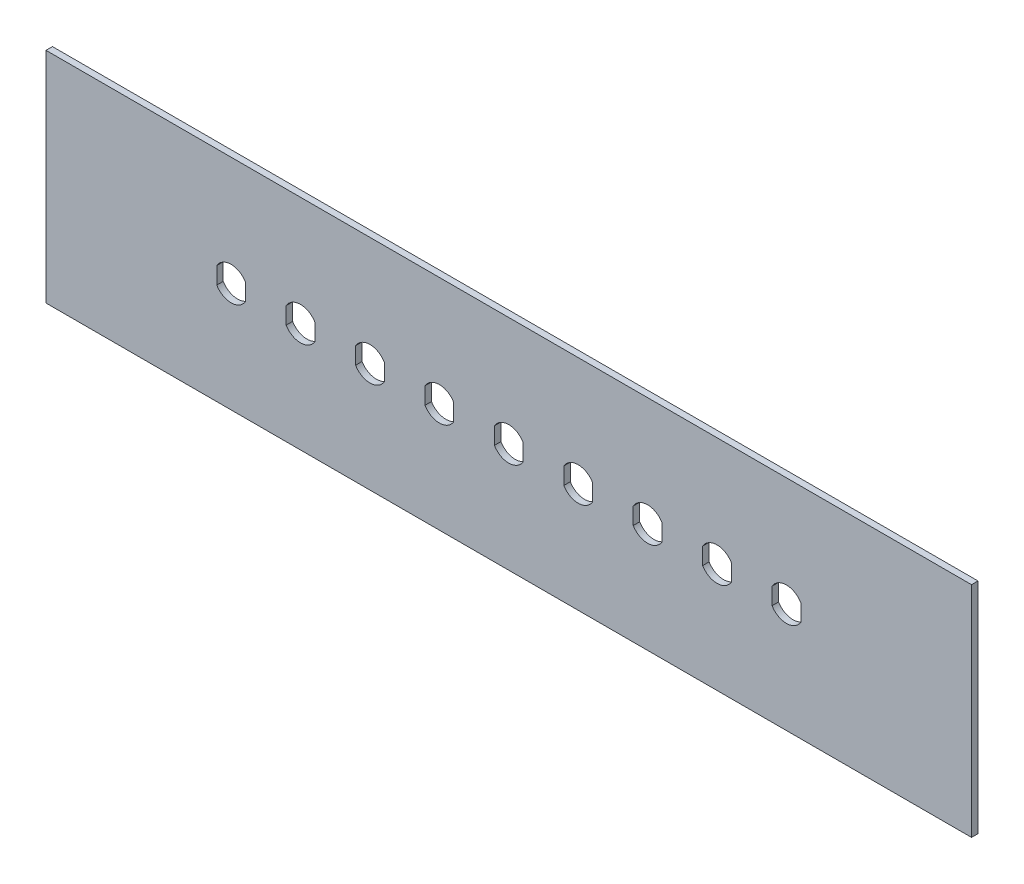
from build123d import *

# Parameters (mm, degrees)
SKETCH1_W           = 254
SKETCH1_H           = 60.071
BOSS_EXTRUDE1_DEPTH = 1.778
CUT_EXTRUDE2_DEPTH  = 262.012808737
LPATTERN1_COUNT     = 9
LPATTERN1_PITCH     = 19.05


with BuildPart() as part:
    # Sketch1 → Boss-Extrude1 (new body)
    with BuildSketch(Plane.XY):
        with Locations((127, 30.0355)):
            Rectangle(SKETCH1_W, SKETCH1_H)
    extrude(amount=BOSS_EXTRUDE1_DEPTH)

    # Sketch1_3 → Cut-Extrude2 (cut, through all)
    with BuildSketch(Plane.XY):
        with BuildLine():
            ThreePointArc((46.863, 27.711018337), (50.8, 25.4635), (54.737, 27.711018337))
            Line((54.737, 27.711018337), (54.737, 32.359981663))
            ThreePointArc((54.737, 32.359981663), (50.8, 34.6075), (46.863, 32.359981663))
            Line((46.863, 32.359981663), (46.863, 27.711018337))
        make_face()
    cut_extrude2 = extrude(amount=CUT_EXTRUDE2_DEPTH, mode=Mode.SUBTRACT)

    # LPattern1: Cut-Extrude2 ×9
    with Locations(*[(i * LPATTERN1_PITCH, 0, 0) for i in range(1, LPATTERN1_COUNT)]):
        add(cut_extrude2, mode=Mode.SUBTRACT)


solid = part.part
